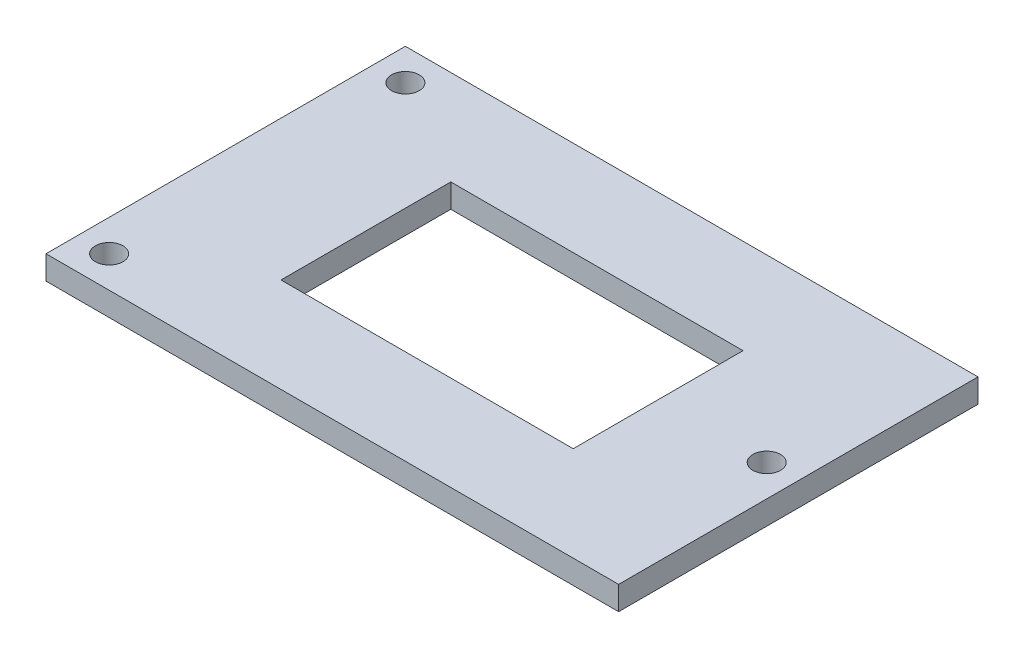
from build123d import *

# Parameters (mm, degrees)
SKETCH1_W           = 72.5
SKETCH1_H           = 45.5
SKETCH1_R           = 1.75
SKETCH1_W_2         = 37
SKETCH1_H_2         = 21.5
BOSS_EXTRUDE1_DEPTH = 3


with BuildPart() as part:
    # Sketch1 → Boss-Extrude1 (new body)
    with BuildSketch(Plane(origin=(0, 0, 0), x_dir=(1, 0, 0), z_dir=(0, 1, 0))):
        with Locations((36.25, 22.75)):
            Rectangle(SKETCH1_W, SKETCH1_H)
        with Locations((68.5, 22.75)):
            Circle(SKETCH1_R, mode=Mode.SUBTRACT)
        with Locations((4, 41.5)):
            Circle(SKETCH1_R, mode=Mode.SUBTRACT)
        with Locations((4, 4)):
            Circle(SKETCH1_R, mode=Mode.SUBTRACT)
        with Locations((36.25, 22.75)):
            Rectangle(SKETCH1_W_2, SKETCH1_H_2, mode=Mode.SUBTRACT)
    extrude(amount=BOSS_EXTRUDE1_DEPTH)


solid = part.part
